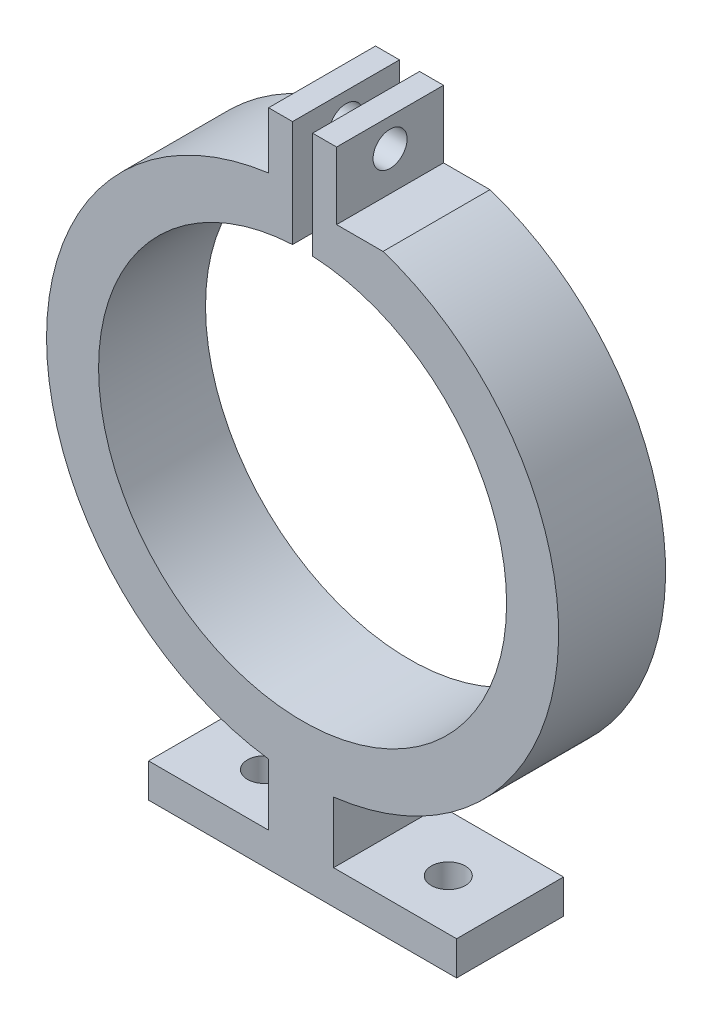
from build123d import *

# Parameters (mm, degrees)
BOSS_EXTRUDE1_DEPTH = 10
SKETCH3_R           = 19.075
CUT_EXTRUDE1_DEPTH  = 11
SKETCH4_W           = 1.877089928
SKETCH4_H           = 9.959436021
CUT_EXTRUDE2_DEPTH  = 11
SKETCH5_R           = 1.59
CUT_EXTRUDE3_DEPTH  = 10
SKETCH6_R           = 1.59
CUT_EXTRUDE4_DEPTH  = 10
SKETCH7_W           = 10
SKETCH7_H           = 1
CUT_EXTRUDE5_DEPTH  = 29.718


with BuildPart() as part:
    # Sketch2 → Boss-Extrude1 (new body)
    with BuildSketch(Plane.XY):
        with BuildLine():
            Line((14.400910076, -32.666118303), (-14.400910076, -32.666118303))
            Line((-14.400910076, -32.666118303), (-14.400910076, -29.486118303))
            Line((-14.400910076, -29.486118303), (-3.18, -29.486118303))
            Line((-3.18, -29.486118303), (-3.18, -23.727857046))
            ThreePointArc((-3.18, -23.727857046), (-23.94, 0), (-3.18, 23.727857046))
            Line((-3.18, 23.727857046), (-3.18, 29.011332471))
            Line((-3.18, 29.011332471), (3.18, 29.011332471))
            Line((3.18, 29.011332471), (3.18, 23.727857046))
            ThreePointArc((3.18, 23.727857046), (23.939582665, -0.141357095), (2.89957421, -23.763755372))
            Line((2.89957421, -23.763755372), (2.89957421, -29.486118303))
            Line((2.89957421, -29.486118303), (14.400910076, -29.486118303))
            Line((14.400910076, -29.486118303), (14.400910076, -32.666118303))
        make_face()
    extrude(amount=BOSS_EXTRUDE1_DEPTH)

    # Sketch3 → Cut-Extrude1 (cut, through all)
    with BuildSketch(Plane.XY.offset(10)):
        Circle(SKETCH3_R)
    extrude(amount=-CUT_EXTRUDE1_DEPTH, mode=Mode.SUBTRACT)

    # Sketch4 → Cut-Extrude2 (cut, through all)
    with BuildSketch(Plane.XY.offset(10)):
        with Locations((0, 24.031614461)):
            Rectangle(SKETCH4_W, SKETCH4_H)
    extrude(amount=-CUT_EXTRUDE2_DEPTH, mode=Mode.SUBTRACT)

    # Sketch5 → Cut-Extrude3 (cut)
    with BuildSketch(Plane(origin=(3.18, 0, 0), x_dir=(0, 0, -1), z_dir=(1, 0, 0))):
        with Locations((-5, 26.369594759)):
            Circle(SKETCH5_R)
    extrude(amount=-CUT_EXTRUDE3_DEPTH, mode=Mode.SUBTRACT)

    # Sketch6 → Cut-Extrude4 (cut)
    with BuildSketch(Plane(origin=(0, -29.486118303, 0), x_dir=(1, 0, 0), z_dir=(0, 1, 0))):
        with Locations((8.912608952, -5.289784221)):
            Circle(SKETCH6_R)
        with Locations((-8.273500585, -5.289784221)):
            Circle(SKETCH6_R)
    extrude(amount=-CUT_EXTRUDE4_DEPTH, mode=Mode.SUBTRACT)

    # Sketch7 → Cut-Extrude5 (cut)
    with BuildSketch(Plane(origin=(3.18, 0, 0), x_dir=(0, 0, -1), z_dir=(1, 0, 0))):
        with Locations((-5, 23.227857046)):
            Rectangle(SKETCH7_W, SKETCH7_H)
    extrude(amount=CUT_EXTRUDE5_DEPTH, mode=Mode.SUBTRACT)


solid = part.part
